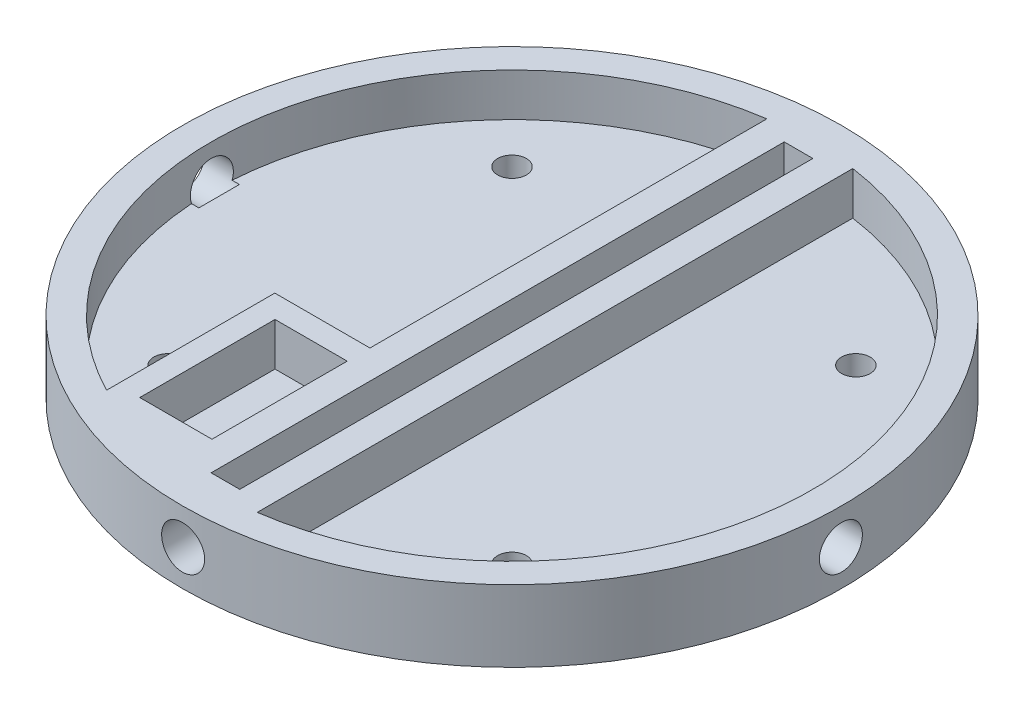
from build123d import *

# Parameters (mm, degrees)
SKETCH5_R           = 73.025
SKETCH5_R_2         = 3.175
PLATEBASE_DEPTH     = 6.35
PLATETOP_DEPTH      = 9.525
SKETCH9_R           = 73.025
SKETCH9_R_2         = 66.675
PLATEWALLS_DEPTH    = 9.525
PLATESLOTENDS_DEPTH = 9.525
BATTERYSLOT_DEPTH   = 9.525
SKETCH13_R          = 4.765
INSERTHOLE_DEPTH    = 8.128
INSERTHOLES_COUNT   = 4


with BuildPart() as part:
    # Sketch5 → PlateBase (new body)
    with BuildSketch(Plane(origin=(0, 0, 0), x_dir=(1, 0, 0), z_dir=(0, 1, 0))):
        Circle(SKETCH5_R)
        with Locations((38.1, 38.1)):
            Circle(SKETCH5_R_2, mode=Mode.SUBTRACT)
        with Locations((38.1, -38.1)):
            Circle(SKETCH5_R_2, mode=Mode.SUBTRACT)
        with Locations((-38.1, 38.1)):
            Circle(SKETCH5_R_2, mode=Mode.SUBTRACT)
        with Locations((-38.1, -38.1)):
            Circle(SKETCH5_R_2, mode=Mode.SUBTRACT)
    extrude(amount=PLATEBASE_DEPTH)

    # Sketch6 → PlateTop (add)
    with BuildSketch(Plane(origin=(0, 6.35, 0), x_dir=(1, 0, 0), z_dir=(0, 1, 0))):
        with BuildLine():
            Line((-3.175, 0), (-3.175, 72.955945611))
            ThreePointArc((-3.175, 72.955945611), (-6.35605636, 72.747860261), (-9.525, 72.401139494))
            Line((-9.525, 72.401139494), (-9.525, 0))
            Line((-9.525, 0), (-9.525, -72.401139494))
            ThreePointArc((-9.525, -72.401139494), (-6.35605636, -72.747860261), (-3.175, -72.955945611))
            Line((-3.175, -72.955945611), (-3.175, 0))
        make_face()
        with BuildLine():
            Line((3.175, 72.955945611), (3.175, 0))
            Line((3.175, 0), (3.175, -72.955945611))
            ThreePointArc((3.175, -72.955945611), (6.35605636, -72.747860261), (9.525, -72.401139494))
            Line((9.525, -72.401139494), (9.525, 0))
            Line((9.525, 0), (9.525, 72.401139494))
            ThreePointArc((9.525, 72.401139494), (6.35605636, 72.747860261), (3.175, 72.955945611))
        make_face()
    extrude(amount=PLATETOP_DEPTH)

    # Sketch9 → PlateWalls (add)
    with BuildSketch(Plane(origin=(0, 6.35, 0), x_dir=(1, 0, 0), z_dir=(0, 1, 0))):
        Circle(SKETCH9_R)
        Circle(SKETCH9_R_2, mode=Mode.SUBTRACT)
    extrude(amount=PLATEWALLS_DEPTH)

    # Sketch11 → PlateSlotEnds (add)
    with BuildSketch(Plane(origin=(0, 6.35, 0), x_dir=(1, 0, 0), z_dir=(0, 1, 0))):
        with BuildLine():
            Line((-3.175, -63.5), (3.175, -63.5))
            Line((3.175, -63.5), (3.175, -66.599361859))
            ThreePointArc((3.175, -66.599361859), (0, -66.675), (-3.175, -66.599361859))
            Line((-3.175, -66.599361859), (-3.175, -63.5))
        make_face()
        with BuildLine():
            Line((-3.175, 63.5), (3.175, 63.5))
            Line((3.175, 63.5), (3.175, 66.599361859))
            ThreePointArc((3.175, 66.599361859), (0, 66.675), (-3.175, 66.599361859))
            Line((-3.175, 66.599361859), (-3.175, 63.5))
        make_face()
    extrude(amount=PLATESLOTENDS_DEPTH)

    # Sketch12 → BatterySlot (add)
    with BuildSketch(Plane(origin=(0, 6.35, 0), x_dir=(1, 0, 0), z_dir=(0, 1, 0))):
        with BuildLine():
            Line((-9.525, -65.991135768), (-9.525, -56.958062669))
            Line((-9.525, -56.958062669), (-25.527, -56.958062669))
            Line((-25.527, -56.958062669), (-25.527, -26.986062669))
            Line((-25.527, -26.986062669), (-9.525, -26.986062669))
            Line((-9.525, -26.986062669), (-9.525, -21.948739215))
            Line((-9.525, -21.948739215), (-30.607, -21.948739215))
            Line((-30.607, -21.948739215), (-30.607, -59.234847649))
            ThreePointArc((-30.607, -59.234847649), (-20.348371269, -63.494089581), (-9.525, -65.991135768))
        make_face()
    extrude(amount=BATTERYSLOT_DEPTH)

    # Sketch13 → InsertHole (cut)
    with BuildSketch(Plane.XY.offset(73.025)):
        with Locations((0, 7.9375)):
            Circle(SKETCH13_R)
    inserthole = extrude(amount=-INSERTHOLE_DEPTH, mode=Mode.SUBTRACT)

    # InsertHoles: InsertHole ×4 about axis
    insertholes_axis = Axis((0, 0, 0), (0, 1, 0))
    for i in range(1, INSERTHOLES_COUNT):
        add(inserthole.rotate(insertholes_axis, i * 360 / INSERTHOLES_COUNT), mode=Mode.SUBTRACT)


solid = part.part
